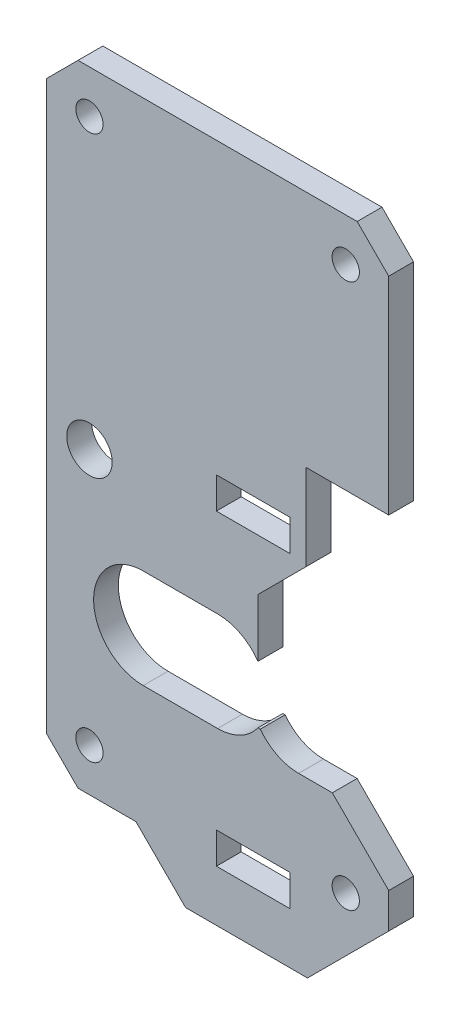
from build123d import *

# Parameters (mm, degrees)
SKETCH1_R           = 1.65
SKETCH1_R_2         = 2.75
BOSS_EXTRUDE1_DEPTH = 3


with BuildPart() as part:
    # Sketch1 → Boss-Extrude1 (new body)
    with BuildSketch(Plane.XY):
        with BuildLine():
            Line((10.7, 26.7), (20.7, 26.7))
            Line((20.7, 26.7), (20.7, 51.73272542))
            Line((20.7, 51.73272542), (16.88272542, 55.55))
            Line((16.88272542, 55.55), (6.037050808, 55.55))
            Line((6.037050808, 55.55), (2.572949192, 55.55))
            Line((2.572949192, 55.55), (-16.88272542, 55.55))
            Line((-16.88272542, 55.55), (-20.7, 51.73272542))
            Line((-20.7, 51.73272542), (-20.7, 16.875735931))
            Line((-20.7, 16.875735931), (-20.7, -16.875735931))
            Line((-20.7, -16.875735931), (-16.875735931, -20.7))
            Line((-16.875735931, -20.7), (-9.875735931, -20.7))
            Line((-9.875735931, -20.7), (-3.875735931, -26.7))
            Line((-3.875735931, -26.7), (2.572949192, -26.7))
            Line((2.572949192, -26.7), (6.037050808, -26.7))
            Line((6.037050808, -26.7), (10.875735931, -26.7))
            Line((10.875735931, -26.7), (20.7, -16.875735931))
            Line((20.7, -16.875735931), (20.7, -12.624264069))
            Line((20.7, -12.624264069), (13.875735931, -5.8))
            Line((13.875735931, -5.8), (9.805, -5.8))
            ThreePointArc((9.805, -5.8), (7.212268524, -5.188231249), (5.166486047, -3.481980515))
            Line((5.166486047, -3.481980515), (4.88628813, -3.481980515))
            ThreePointArc((4.88628813, -3.481980515), (2.748464745, -5.333473685), (0, -6))
            Line((0, -6), (-9, -6))
            ThreePointArc((-9, -6), (-15, 0), (-9, 6))
            Line((-9, 6), (0, 6))
            ThreePointArc((0, 6), (2.748464745, 5.333473685), (4.88628813, 3.481980515))
            Line((4.88628813, 3.481980515), (4.88628813, 10.481980515))
            Line((4.88628813, 10.481980515), (10.7, 16.295692385))
            Line((10.7, 16.295692385), (10.7, 26.7))
        make_face()
        with Locations((-15.5, -15.5)):
            Circle(SKETCH1_R, mode=Mode.SUBTRACT)
        Polygon((6.037050808, -20.5), (2.572949192, -20.5), (-0.145, -20.5), (-0.145, -16.7), (8.755, -16.7), (8.755, -20.5), align=None, mode=Mode.SUBTRACT)
        with Locations((15.5, -15.5)):
            Circle(SKETCH1_R, mode=Mode.SUBTRACT)
        with Locations((-15.5, 15.5)):
            Circle(SKETCH1_R_2, mode=Mode.SUBTRACT)
        with Locations((-15.5, 50.35)):
            Circle(SKETCH1_R, mode=Mode.SUBTRACT)
        Polygon((-0.145, 20.5), (2.572949192, 20.5), (6.037050808, 20.5), (8.755, 20.5), (8.755, 16.7), (-0.145, 16.7), align=None, mode=Mode.SUBTRACT)
        with Locations((15.5, 50.35)):
            Circle(SKETCH1_R, mode=Mode.SUBTRACT)
    extrude(amount=BOSS_EXTRUDE1_DEPTH)


solid = part.part
